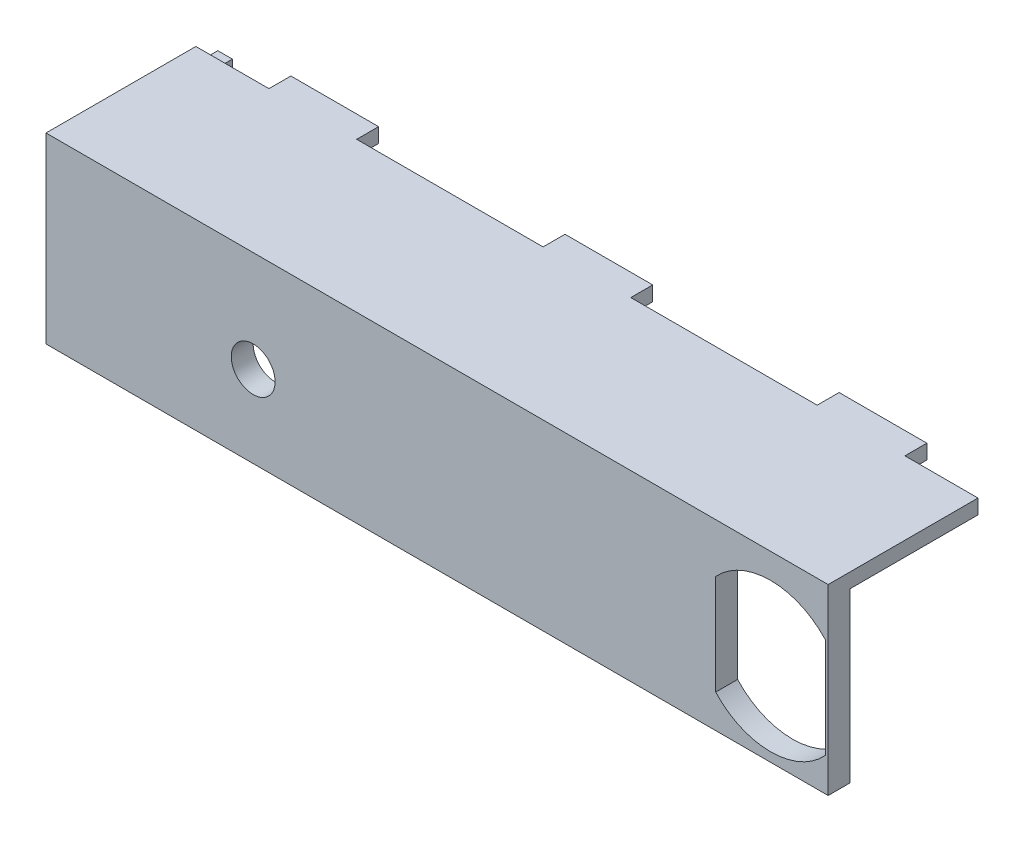
from build123d import *

# Parameters (mm, degrees)
ESBO_O1_W                = 107
ESBO_O1_H                = 25
ESBO_O1_R                = 3
RESSALTO_EXTRUS_O1_DEPTH = 3
ESBO_O1_11_W             = 12
ESBO_O1_11_H             = 2
ESBO_O1_11_W_2           = 10
ESBO_O1_11_W_3           = 25.5
ESBO_O1_11_W_4           = 2
ESBO_O1_11_H_2           = 6
ESBO_O1_11_H_3           = 9
RESSALTO_EXTRUS_O2_DEPTH = 20.5
ESBO_O1_12_W             = 12
ESBO_O1_12_H             = 2
ESBO_O1_12_W_2           = 2
ESBO_O1_12_H_2           = 6
RESSALTO_EXTRUS_O3_DEPTH = 23.5
ESBO_O1_13_R             = 3.5
RESSALTO_EXTRUS_O4_DEPTH = 5
ESBO_O1_14_R             = 1.5
CORTE_EXTRUS_O1_DEPTH    = 5
ESBO_O1_15_R             = 1.5
RESSALTO_EXTRUS_O5_DEPTH = 3


with BuildPart() as part:
    # Esboço1 → Ressalto-extrusão1 (new body)
    with BuildSketch(Plane.XY):
        with Locations((12.82231405, 20.771694215)):
            Rectangle(ESBO_O1_W, ESBO_O1_H)
        with BuildLine():
            Line((50.941584595, 12.8399279), (50.941584595, 26.5399279))
            ThreePointArc((50.941584595, 26.5399279), (58.441584595, 29.827875939), (65.941584595, 26.5399279))
            Line((65.941584595, 26.5399279), (65.941584595, 12.8399279))
            ThreePointArc((65.941584595, 12.8399279), (58.441584595, 9.518237762), (50.941584595, 12.8399279))
        make_face(mode=Mode.SUBTRACT)
        with Locations((-12.336122998, 19.452784517)):
            Circle(ESBO_O1_R, mode=Mode.SUBTRACT)
    extrude(amount=-RESSALTO_EXTRUS_O1_DEPTH)

    # Esboço1<11> → Ressalto-extrusão2 (add)
    with BuildSketch(Plane.XY):
        with Locations((50.32231405, 32.271694215)):
            Rectangle(ESBO_O1_11_W, ESBO_O1_11_H)
        with Locations((61.32231405, 32.271694215)):
            Rectangle(ESBO_O1_11_W_2, ESBO_O1_11_H)
        with Locations((31.57231405, 32.271694215)):
            Rectangle(ESBO_O1_11_W_3, ESBO_O1_11_H)
        with Locations((12.82231405, 32.271694215)):
            Rectangle(ESBO_O1_11_W, ESBO_O1_11_H)
        with Locations((-5.92768595, 32.271694215)):
            Rectangle(ESBO_O1_11_W_3, ESBO_O1_11_H)
        with Locations((-24.67768595, 32.271694215)):
            Rectangle(ESBO_O1_11_W, ESBO_O1_11_H)
        Polygon((-30.67768595, 33.271694215), (-40.67768595, 33.271694215), (-40.67768595, 31.271694215), (-38.67768595, 31.271694215), (-30.67768595, 31.271694215), align=None)
        with Locations((-39.67768595, 28.271694215)):
            Rectangle(ESBO_O1_11_W_4, ESBO_O1_11_H_2)
        with Locations((-39.67768595, 20.771694215)):
            Rectangle(ESBO_O1_11_W_4, ESBO_O1_11_H_3)
        with Locations((-39.67768595, 13.271694215)):
            Rectangle(ESBO_O1_11_W_4, ESBO_O1_11_H_2)
        with Locations((-39.67768595, 9.271694215)):
            Rectangle(ESBO_O1_11_W_4, ESBO_O1_11_H)
    extrude(amount=-RESSALTO_EXTRUS_O2_DEPTH)

    # Esboço1<12> → Ressalto-extrusão3 (add)
    with BuildSketch(Plane.XY):
        with Locations((50.32231405, 32.271694215)):
            Rectangle(ESBO_O1_12_W, ESBO_O1_12_H)
        with Locations((12.82231405, 32.271694215)):
            Rectangle(ESBO_O1_12_W, ESBO_O1_12_H)
        with Locations((-24.67768595, 32.271694215)):
            Rectangle(ESBO_O1_12_W, ESBO_O1_12_H)
        with Locations((-39.67768595, 28.271694215)):
            Rectangle(ESBO_O1_12_W_2, ESBO_O1_12_H_2)
        with Locations((-39.67768595, 13.271694215)):
            Rectangle(ESBO_O1_12_W_2, ESBO_O1_12_H_2)
    extrude(amount=-RESSALTO_EXTRUS_O3_DEPTH)

    # Esboço1<13> → Ressalto-extrusão4 (add)
    with BuildSketch(Plane.XY):
        with Locations((14.32231405, 15.171694215)):
            Circle(ESBO_O1_13_R)
        with Locations((31.82231405, 15.171694215)):
            Circle(ESBO_O1_13_R)
    extrude(amount=-RESSALTO_EXTRUS_O4_DEPTH)

    # Esboço1<14> → Corte-extrusão1 (cut)
    with BuildSketch(Plane.XY):
        with Locations((14.32231405, 15.171694215)):
            Circle(ESBO_O1_14_R)
        with Locations((31.82231405, 15.171694215)):
            Circle(ESBO_O1_14_R)
    extrude(amount=-CORTE_EXTRUS_O1_DEPTH, mode=Mode.SUBTRACT)

    # Esboço1<15> → Ressalto-extrusão5 (add)
    with BuildSketch(Plane.XY):
        with Locations((14.32231405, 15.171694215)):
            Circle(ESBO_O1_15_R)
        with Locations((31.82231405, 15.171694215)):
            Circle(ESBO_O1_15_R)
    extrude(amount=-RESSALTO_EXTRUS_O5_DEPTH)


solid = part.part
